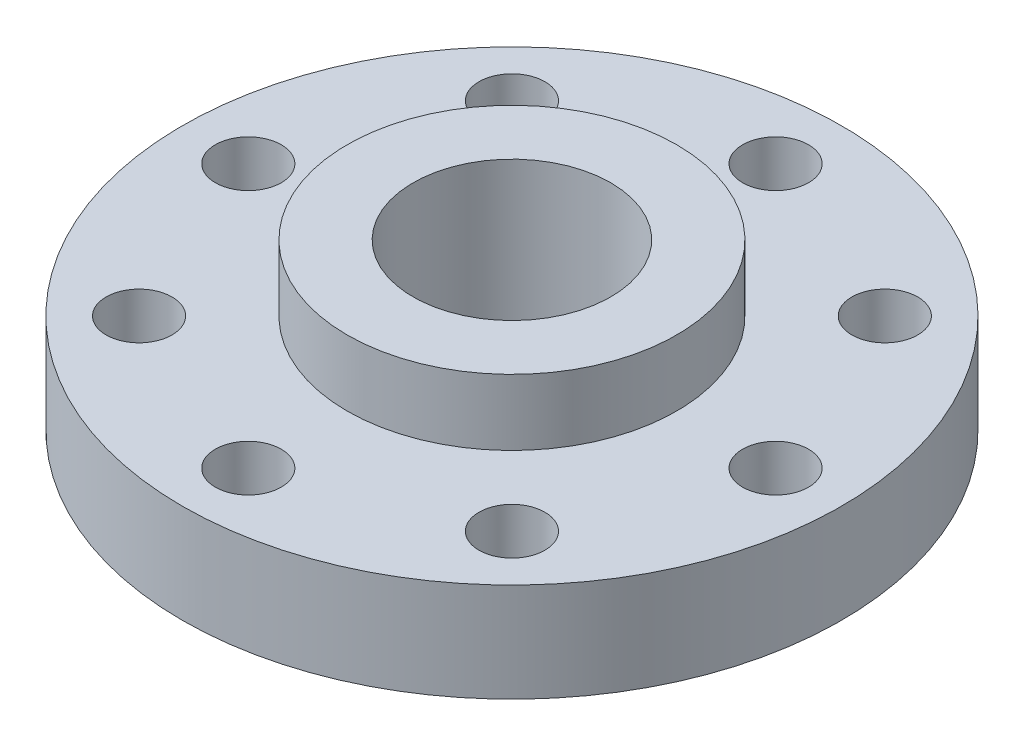
from build123d import *

# Parameters (mm, degrees)
SKETCH_1_R          = 10
EXTRUDE_1_DEPTH     = 3
SKETCH_2_R          = 5
EXTRUDE_2_DEPTH     = 2
SKETCH_3_R          = 3
SKETCH_3_R_2        = 1
CUT_EXTRUDE_1_DEPTH = 6


with BuildPart() as part:
    # 草图1 → 凸台-拉伸1 (new body)
    with BuildSketch(Plane(origin=(0, 0, 0), x_dir=(1, 0, 0), z_dir=(0, 1, 0))):
        Circle(SKETCH_1_R)
    extrude(amount=EXTRUDE_1_DEPTH)

    # 草图2 → 凸台-拉伸2 (add)
    with BuildSketch(Plane(origin=(0, 3, 0), x_dir=(1, 0, 0), z_dir=(0, 1, 0))):
        Circle(SKETCH_2_R)
    extrude(amount=EXTRUDE_2_DEPTH)

    # 草图3 → 切除-拉伸1 (cut, through all)
    with BuildSketch(Plane.XZ):
        Circle(SKETCH_3_R)
        with Locations((0, 8)):
            Circle(SKETCH_3_R_2)
        with Locations((5.656854249, 5.656854249)):
            Circle(SKETCH_3_R_2)
        with Locations((8, 0)):
            Circle(SKETCH_3_R_2)
        with Locations((5.656854249, -5.656854249)):
            Circle(SKETCH_3_R_2)
        with Locations((0, -8)):
            Circle(SKETCH_3_R_2)
        with Locations((-5.656854249, -5.656854249)):
            Circle(SKETCH_3_R_2)
        with Locations((-8, 0)):
            Circle(SKETCH_3_R_2)
        with Locations((-5.656854249, 5.656854249)):
            Circle(SKETCH_3_R_2)
    extrude(amount=-CUT_EXTRUDE_1_DEPTH, mode=Mode.SUBTRACT)


solid = part.part
